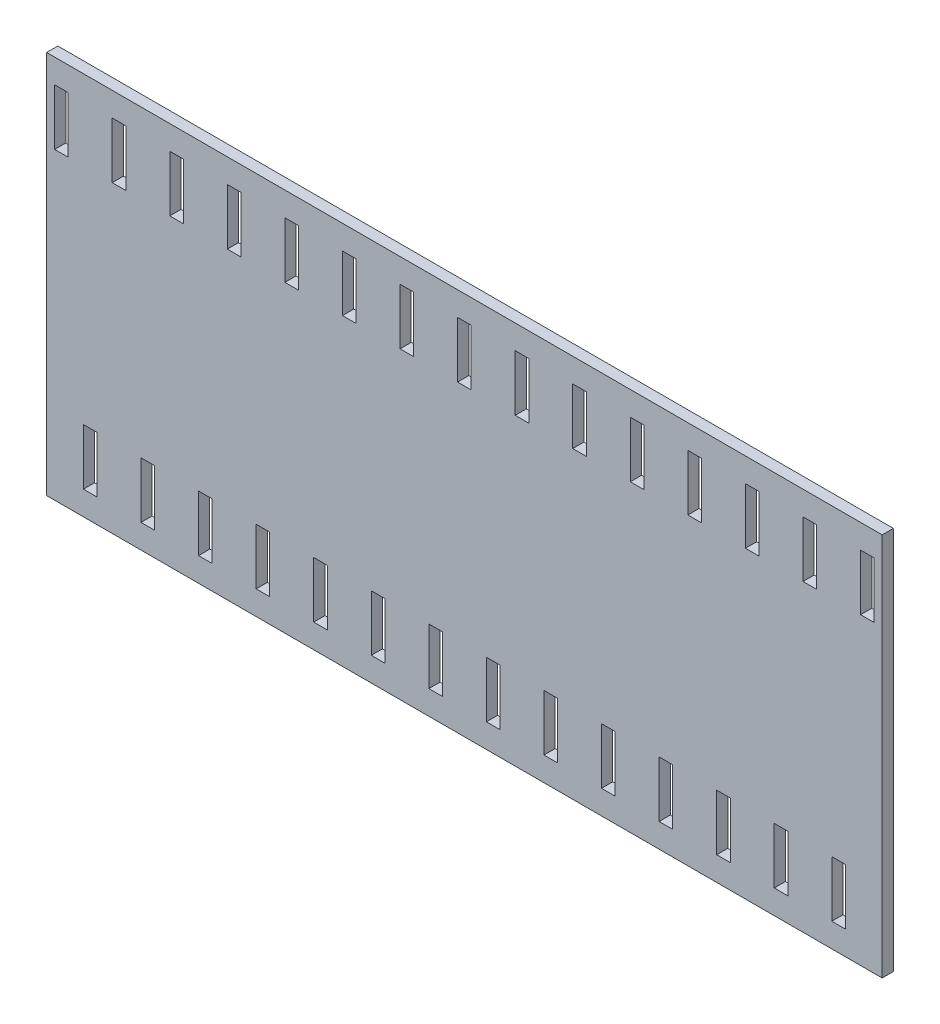
from build123d import *

# Parameters (mm, degrees)
ESQUISSE1_W             = 104.5
ESQUISSE1_H             = 48
BOSS_EXTRU_1_DEPTH      = 1.4
ESQUISSE2_W             = 1.7
ESQUISSE2_H             = 7
ENL_V_MAT_EXTRU_1_DEPTH = 2.4
ESQUISSE4_W             = 1.346153846
ESQUISSE4_H             = 0.358974359
ENL_V_MAT_EXTRU_2_DEPTH = 0.1


with BuildPart() as part:
    # Esquisse1 → Boss.-Extru.1 (new body)
    with BuildSketch(Plane.XY):
        Rectangle(ESQUISSE1_W, ESQUISSE1_H)
    extrude(amount=BOSS_EXTRU_1_DEPTH)

    # Esquisse2 → Enlèv. mat.-Extru.1 (cut, through all)
    with BuildSketch(Plane(origin=(0, 0, 0), x_dir=(-1, 0, 0), z_dir=(0, 0, -1))):
        with Locations((-50.4, 17.5)):
            Rectangle(ESQUISSE2_W, ESQUISSE2_H)
        with Locations((-43.2, 17.5)):
            Rectangle(ESQUISSE2_W, ESQUISSE2_H)
        with Locations((-36, 17.5)):
            Rectangle(ESQUISSE2_W, ESQUISSE2_H)
        with Locations((-28.8, 17.5)):
            Rectangle(ESQUISSE2_W, ESQUISSE2_H)
        with Locations((-21.6, 17.5)):
            Rectangle(ESQUISSE2_W, ESQUISSE2_H)
        with Locations((-14.4, 17.5)):
            Rectangle(ESQUISSE2_W, ESQUISSE2_H)
        with Locations((-7.2, 17.5)):
            Rectangle(ESQUISSE2_W, ESQUISSE2_H)
        with Locations((0, 17.5)):
            Rectangle(ESQUISSE2_W, ESQUISSE2_H)
        with Locations((7.2, 17.5)):
            Rectangle(ESQUISSE2_W, ESQUISSE2_H)
        with Locations((14.4, 17.5)):
            Rectangle(ESQUISSE2_W, ESQUISSE2_H)
        with Locations((21.6, 17.5)):
            Rectangle(ESQUISSE2_W, ESQUISSE2_H)
        with Locations((28.8, 17.5)):
            Rectangle(ESQUISSE2_W, ESQUISSE2_H)
        with Locations((36, 17.5)):
            Rectangle(ESQUISSE2_W, ESQUISSE2_H)
        with Locations((43.2, 17.5)):
            Rectangle(ESQUISSE2_W, ESQUISSE2_H)
        with Locations((50.4, 17.5)):
            Rectangle(ESQUISSE2_W, ESQUISSE2_H)
        with Locations((-46.8, -17.5)):
            Rectangle(ESQUISSE2_W, ESQUISSE2_H)
        with Locations((-39.6, -17.5)):
            Rectangle(ESQUISSE2_W, ESQUISSE2_H)
        with Locations((-32.4, -17.5)):
            Rectangle(ESQUISSE2_W, ESQUISSE2_H)
        with Locations((-25.2, -17.5)):
            Rectangle(ESQUISSE2_W, ESQUISSE2_H)
        with Locations((-18, -17.5)):
            Rectangle(ESQUISSE2_W, ESQUISSE2_H)
        with Locations((-10.8, -17.5)):
            Rectangle(ESQUISSE2_W, ESQUISSE2_H)
        with Locations((-3.6, -17.5)):
            Rectangle(ESQUISSE2_W, ESQUISSE2_H)
        with Locations((3.6, -17.5)):
            Rectangle(ESQUISSE2_W, ESQUISSE2_H)
        with Locations((10.8, -17.5)):
            Rectangle(ESQUISSE2_W, ESQUISSE2_H)
        with Locations((18, -17.5)):
            Rectangle(ESQUISSE2_W, ESQUISSE2_H)
        with Locations((25.2, -17.5)):
            Rectangle(ESQUISSE2_W, ESQUISSE2_H)
        with Locations((32.4, -17.5)):
            Rectangle(ESQUISSE2_W, ESQUISSE2_H)
        with Locations((39.6, -17.5)):
            Rectangle(ESQUISSE2_W, ESQUISSE2_H)
        with Locations((46.8, -17.5)):
            Rectangle(ESQUISSE2_W, ESQUISSE2_H)
    extrude(amount=-ENL_V_MAT_EXTRU_1_DEPTH, mode=Mode.SUBTRACT)

    # Esquisse4 → Enlèv. mat.-Extru.2 (cut)
    with BuildSketch(Plane(origin=(0, 0, 0), x_dir=(-1, 0, 0), z_dir=(0, 0, -1))):
        with BuildLine():
            Line((-12.952395535, 1.716787319), (-12.265997297, 1.716787319))
            add(Edge.make_bspline(
                [(-12.265997297, 1.716787319), (-12.218786391, 1.716735423), (-12.128328198, 1.716635987), (-11.998613143, 1.713621241), (-11.880803411, 1.709594549), (-11.77515303, 1.704012656), (-11.681336932, 1.697416066), (-11.599779632, 1.688164026), (-11.529840076, 1.678503731), (-11.487933627, 1.668682324), (-11.468821817, 1.664203184)],
                knots=[0, 0, 0, 0, 0.000141628, 0.000271366, 0.00038923, 0.000495248, 0.00058876, 0.000671296, 0.000741499, 0.00080036, 0.00080036, 0.00080036, 0.00080036], degree=3))
            add(Edge.make_bspline(
                [(-11.468821817, 1.664203184), (-11.444628283, 1.657581234), (-11.396811306, 1.644493373), (-11.327910262, 1.618279649), (-11.262356417, 1.587197484), (-11.199924859, 1.551773544), (-11.141382775, 1.51048798), (-11.085856735, 1.465014362), (-11.033836754, 1.414302794), (-10.985615362, 1.358922054), (-10.941330565, 1.299801844), (-10.903200882, 1.236059614), (-10.871273655, 1.168768311), (-10.843890383, 1.097974739), (-10.824181929, 1.023084416), (-10.809335029, 0.944617704), (-10.799911402, 0.862583013), (-10.79900884, 0.806523146), (-10.798549381, 0.777985235)],
                knots=[0, 0, 0, 0, 7.5216e-05, 0.00014866, 0.000220794, 0.000292713, 0.000363707, 0.000435434, 0.000507823, 0.000581364, 0.000655543, 0.000729131, 0.000803767, 0.000878771, 0.000956497, 0.001035702, 0.001118238, 0.001203821, 0.001203821, 0.001203821, 0.001203821], degree=3))
            add(Edge.make_bspline(
                [(-10.798549381, 0.777985235), (-10.798970805, 0.749207459), (-10.799795351, 0.692901795), (-10.809691637, 0.610529007), (-10.823021828, 0.531810616), (-10.843518881, 0.456921166), (-10.870364554, 0.386305395), (-10.901856607, 0.318884163), (-10.939840137, 0.255804492), (-10.983484967, 0.196837374), (-11.032036561, 0.141927462), (-11.085289499, 0.091472667), (-11.143028792, 0.045768329), (-11.20507094, 0.004711985), (-11.272020789, -0.030744294), (-11.342862942, -0.062501599), (-11.418213159, -0.08917266), (-11.470355673, -0.103202721), (-11.496866688, -0.110336079)],
                knots=[0, 0, 0, 0, 8.6284e-05, 0.00016882, 0.000248587, 0.000325638, 0.000401297, 0.000474998, 0.000548586, 0.000621785, 0.0006948, 0.0007682, 0.000841564, 0.000915458, 0.000991056, 0.00106858, 0.00114819, 0.001230532, 0.001230532, 0.001230532, 0.001230532], degree=3))
            add(Edge.make_bspline(
                [(-11.496866688, -0.110336079), (-11.518794022, -0.11499906), (-11.56684905, -0.125218254), (-11.645991772, -0.136626711), (-11.738137158, -0.146364311), (-11.843159438, -0.153665449), (-11.960964343, -0.159915817), (-12.0916156, -0.164883911), (-12.235369677, -0.167613765), (-12.335640921, -0.167754558), (-12.38799249, -0.167828066)],
                knots=[0, 0, 0, 0, 6.7238e-05, 0.000147357, 0.000239727, 0.000345177, 0.000463135, 0.000593636, 0.000737393, 0.000894446, 0.000894446, 0.000894446, 0.000894446], degree=3))
            Line((-12.38799249, -0.167828066), (-12.63829297, -0.167828066))
            Line((-12.63829297, -0.167828066), (-12.63829297, -1.783212681))
            Line((-12.63829297, -1.783212681), (-12.952395535, -1.783212681))
            Line((-12.952395535, -1.783212681), (-12.952395535, 1.716787319))
        make_face()
        with BuildLine():
            Line((-12.63829297, 1.35781296), (-12.63829297, 0.191146293))
            Line((-12.63829297, 0.191146293), (-12.025512522, 0.183433953))
            add(Edge.make_bspline(
                [(-12.025512522, 0.183433953), (-11.995592596, 0.18341849), (-11.937832796, 0.183388638), (-11.854396573, 0.187373861), (-11.776987285, 0.191974394), (-11.70584271, 0.198710317), (-11.640930776, 0.208231575), (-11.582143247, 0.217843313), (-11.529935964, 0.231748675), (-11.468836762, 0.250471744), (-11.400753415, 0.28240436), (-11.326685866, 0.32875425), (-11.26391528, 0.387834958), (-11.209596983, 0.45426279), (-11.166491105, 0.528161919), (-11.134935113, 0.607230856), (-11.116393955, 0.690658705), (-11.113907762, 0.747746844), (-11.112651945, 0.776582992)],
                knots=[0, 0, 0, 0, 8.9746e-05, 0.000173253, 0.000250533, 0.00032239, 0.000387534, 0.00044736, 0.000500926, 0.000549486, 0.000638903, 0.000725641, 0.000810488, 0.000896226, 0.000982324, 0.00106604, 0.001150757, 0.001237226, 0.001237226, 0.001237226, 0.001237226], degree=3))
            add(Edge.make_bspline(
                [(-11.112651945, 0.776582992), (-11.113914591, 0.804721505), (-11.116424576, 0.860657387), (-11.135080439, 0.942636148), (-11.166429753, 1.020871852), (-11.209886348, 1.093844938), (-11.262627478, 1.160033742), (-11.323926821, 1.217530869), (-11.393640082, 1.263752572), (-11.458488313, 1.293585853), (-11.516089499, 1.311801129), (-11.566121459, 1.324545969), (-11.622612134, 1.334721575), (-11.685579913, 1.342961078), (-11.754536747, 1.350014539), (-11.830075062, 1.354800517), (-11.911908705, 1.357601973), (-11.968719276, 1.357740928), (-11.998168772, 1.35781296)],
                knots=[0, 0, 0, 0, 8.4371e-05, 0.000167719, 0.000250783, 0.000336277, 0.000421575, 0.000503926, 0.000587348, 0.000671427, 0.000717102, 0.000768457, 0.000826213, 0.000889178, 0.000958942, 0.001034123, 0.001116202, 0.001204546, 0.001204546, 0.001204546, 0.001204546], degree=3))
            Line((-11.998168772, 1.35781296), (-12.63829297, 1.35781296))
        make_face(mode=Mode.SUBTRACT)
        with BuildLine():
            Line((-6.849831432, 1.074559755), (-7.124671176, 0.864223216))
            add(Edge.make_bspline(
                [(-7.124671176, 0.864223216), (-7.144277064, 0.887589186), (-7.183224511, 0.934006102), (-7.245883713, 0.999185646), (-7.311185356, 1.060250908), (-7.379104477, 1.117492787), (-7.450863597, 1.168909553), (-7.524724396, 1.217180656), (-7.601922441, 1.260448394), (-7.708674175, 1.31291138), (-7.848322024, 1.367657535), (-8.024116863, 1.413560766), (-8.207627961, 1.442781942), (-8.332825561, 1.445946783), (-8.396506111, 1.44755655)],
                knots=[0, 0, 0, 0, 9.1485e-05, 0.000181737, 0.000271024, 0.000359627, 0.000447979, 0.000535687, 0.000624217, 0.000713268, 0.000892422, 0.00107303, 0.001257466, 0.001448389, 0.001448389, 0.001448389, 0.001448389], degree=3))
            add(Edge.make_bspline(
                [(-8.396506111, 1.44755655), (-8.431589411, 1.447152587), (-8.501430403, 1.446348411), (-8.605078877, 1.435739286), (-8.706791928, 1.420828076), (-8.806503394, 1.398702753), (-8.904086353, 1.370730134), (-9.000178755, 1.33730472), (-9.093389355, 1.29594988), (-9.185007593, 1.25024162), (-9.272786804, 1.198614175), (-9.355841852, 1.142300823), (-9.43386982, 1.081931727), (-9.506932432, 1.01728062), (-9.57510438, 0.94863866), (-9.637891691, 0.875274318), (-9.695077101, 0.797422145), (-9.747794126, 0.716108737), (-9.795006859, 0.631570946), (-9.834536739, 0.543495875), (-9.869541861, 0.453391772), (-9.897241104, 0.360240611), (-9.919165621, 0.264697846), (-9.934293284, 0.166507058), (-9.944781755, 0.065873378), (-9.945581932, -0.002335935), (-9.945985278, -0.03671829)],
                knots=[0, 0, 0, 0, 0.000105206, 0.000209435, 0.000312261, 0.00041348, 0.000515565, 0.000616682, 0.000718413, 0.000821258, 0.000923708, 0.001023662, 0.001122111, 0.001219464, 0.00131614, 0.001412112, 0.001508869, 0.001605718, 0.001702691, 0.001799013, 0.001895107, 0.001992482, 0.002090281, 0.00218895, 0.002290387, 0.00239349, 0.00239349, 0.00239349, 0.00239349], degree=3))
            add(Edge.make_bspline(
                [(-9.945985278, -0.03671829), (-9.944723459, -0.08844961), (-9.942246045, -0.190017195), (-9.920197711, -0.338787806), (-9.886692619, -0.481308479), (-9.836477042, -0.616688322), (-9.774557992, -0.74659668), (-9.69631738, -0.868835533), (-9.605700843, -0.985252098), (-9.501426424, -1.093095045), (-9.387020608, -1.191608771), (-9.264272696, -1.278359352), (-9.133488408, -1.350674235), (-8.996111778, -1.410850181), (-8.851085664, -1.457106909), (-8.698670862, -1.489671032), (-8.539198866, -1.510913213), (-8.430229467, -1.512946901), (-8.374771336, -1.513981912)],
                knots=[0, 0, 0, 0, 0.000155106, 0.000304531, 0.000450265, 0.000593548, 0.000736853, 0.000881182, 0.001028026, 0.001178769, 0.001330408, 0.001480379, 0.001628835, 0.001777978, 0.001929641, 0.002084627, 0.002245075, 0.00241136, 0.00241136, 0.00241136, 0.00241136], degree=3))
            add(Edge.make_bspline(
                [(-8.374771336, -1.513981912), (-8.313668647, -1.512293132), (-8.193403938, -1.50896921), (-8.017035912, -1.480809961), (-7.848200146, -1.435152043), (-7.686887559, -1.37125412), (-7.533552913, -1.288188833), (-7.387956253, -1.187490955), (-7.249974682, -1.068202622), (-7.1670034, -0.977119494), (-7.124671176, -0.930648579)],
                knots=[0, 0, 0, 0, 0.00018322, 0.00036062, 0.000534275, 0.000707044, 0.000879893, 0.001056289, 0.001237208, 0.001425665, 0.001425665, 0.001425665, 0.001425665], degree=3))
            Line((-7.124671176, -0.930648579), (-6.849831432, -1.138881752))
            add(Edge.make_bspline(
                [(-6.849831432, -1.138881752), (-6.871949542, -1.167420204), (-6.916079817, -1.22436041), (-6.987537834, -1.30463212), (-7.062815131, -1.380136155), (-7.142470841, -1.450263776), (-7.225588633, -1.516418242), (-7.313660945, -1.576720073), (-7.405529978, -1.632010958), (-7.500884457, -1.682637882), (-7.59962307, -1.727555129), (-7.701627505, -1.766008897), (-7.80645808, -1.799133786), (-7.914119588, -1.826385723), (-8.024835345, -1.847656807), (-8.138205819, -1.861876482), (-8.254475695, -1.871618396), (-8.332917116, -1.872506312), (-8.37266797, -1.872956271)],
                knots=[0, 0, 0, 0, 0.000108293, 0.000216068, 0.000322162, 0.000427957, 0.000534281, 0.00064066, 0.000747915, 0.000855806, 0.000964371, 0.001073102, 0.001182643, 0.001294024, 0.001406092, 0.001520624, 0.001636667, 0.001755891, 0.001755891, 0.001755891, 0.001755891], degree=3))
            add(Edge.make_bspline(
                [(-8.37266797, -1.872956271), (-8.410311637, -1.872694278), (-8.484747328, -1.872176221), (-8.594646079, -1.863784053), (-8.70163566, -1.852334316), (-8.805410286, -1.835094185), (-8.906536261, -1.814749845), (-9.004096845, -1.787478589), (-9.099052056, -1.756929422), (-9.191020396, -1.721024435), (-9.280080096, -1.680508253), (-9.365943908, -1.634716694), (-9.44857234, -1.584034829), (-9.528777761, -1.529579819), (-9.605375345, -1.469602517), (-9.67902887, -1.404935882), (-9.750151346, -1.335797872), (-9.794154031, -1.285943018), (-9.816277746, -1.260876944)],
                knots=[0, 0, 0, 0, 0.0001129, 0.000223246, 0.000330481, 0.000435603, 0.000538732, 0.000639764, 0.000739316, 0.000837878, 0.000935767, 0.001032686, 0.001129604, 0.00122645, 0.001323362, 0.001421241, 0.001520399, 0.001620667, 0.001620667, 0.001620667, 0.001620667], degree=3))
            add(Edge.make_bspline(
                [(-9.816277746, -1.260876944), (-9.85171339, -1.217335755), (-9.922156866, -1.130779045), (-10.01228255, -0.990493063), (-10.089430105, -0.844024855), (-10.151806026, -0.690604926), (-10.200568759, -0.530577539), (-10.234349954, -0.363862024), (-10.256301559, -0.190614082), (-10.258811847, -0.072777293), (-10.260087842, -0.012880149)],
                knots=[0, 0, 0, 0, 0.000168306, 0.00033458, 0.000499224, 0.000664315, 0.00083066, 0.00100034, 0.001174094, 0.001353718, 0.001353718, 0.001353718, 0.001353718], degree=3))
            add(Edge.make_bspline(
                [(-10.260087842, -0.012880149), (-10.258532649, 0.050075304), (-10.255472902, 0.173936229), (-10.229477107, 0.355710182), (-10.187658311, 0.529861581), (-10.128261422, 0.696065326), (-10.052956071, 0.855195606), (-9.959929457, 1.006036811), (-9.850262315, 1.14955361), (-9.724814747, 1.283568362), (-9.587247412, 1.406107714), (-9.439928598, 1.513913918), (-9.283146651, 1.603631434), (-9.118628799, 1.678627596), (-8.945143118, 1.73627206), (-8.763059749, 1.776625246), (-8.572720834, 1.801742363), (-8.442858408, 1.80491757), (-8.376874701, 1.806530909)],
                knots=[0, 0, 0, 0, 0.000188789, 0.000371431, 0.000549644, 0.000725278, 0.00089996, 0.001076844, 0.001255917, 0.001440951, 0.001626689, 0.001807878, 0.001987546, 0.002167657, 0.002349462, 0.002534866, 0.002726448, 0.002924344, 0.002924344, 0.002924344, 0.002924344], degree=3))
            add(Edge.make_bspline(
                [(-8.376874701, 1.806530909), (-8.336660229, 1.80604877), (-8.257059732, 1.805094426), (-8.13930708, 1.795788284), (-8.024664753, 1.780274678), (-7.913053771, 1.759158608), (-7.803931154, 1.732951287), (-7.698130913, 1.698810988), (-7.595032227, 1.659774457), (-7.495285318, 1.614815991), (-7.399368768, 1.56434925), (-7.30731245, 1.508933626), (-7.219847591, 1.448637821), (-7.136358743, 1.383974645), (-7.058242532, 1.313576086), (-6.983281053, 1.23937849), (-6.914019975, 1.159244666), (-6.87126678, 1.102839732), (-6.849831432, 1.074559755)],
                knots=[0, 0, 0, 0, 0.000120626, 0.000238766, 0.000354085, 0.000467531, 0.000579423, 0.000690512, 0.000800803, 0.000910007, 0.001018518, 0.001125773, 0.001232152, 0.001337058, 0.001442329, 0.001547432, 0.001653292, 0.001759736, 0.001759736, 0.001759736, 0.001759736], degree=3))
        make_face()
        with BuildLine():
            Line((-6.131882714, 1.716787319), (-5.448990086, 1.716787319))
            add(Edge.make_bspline(
                [(-5.448990086, 1.716787319), (-5.415561608, 1.716611568), (-5.350768897, 1.71627092), (-5.256549455, 1.710987789), (-5.168300645, 1.703784119), (-5.085996872, 1.692354027), (-5.00967617, 1.67856225), (-4.939108533, 1.661860433), (-4.874518361, 1.64183382), (-4.797405624, 1.609987539), (-4.709484963, 1.56266437), (-4.614286571, 1.492735805), (-4.532882331, 1.407203342), (-4.462696014, 1.310720687), (-4.406894894, 1.204584915), (-4.366525597, 1.091325726), (-4.340967722, 0.972403984), (-4.338339287, 0.890760806), (-4.337010919, 0.849499659)],
                knots=[0, 0, 0, 0, 0.00010027, 0.000194349, 0.000283026, 0.000365821, 0.000443519, 0.000515622, 0.000583254, 0.00064614, 0.000765662, 0.000881909, 0.000998927, 0.001118415, 0.001238844, 0.00135727, 0.001478274, 0.001601912, 0.001601912, 0.001601912, 0.001601912], degree=3))
            add(Edge.make_bspline(
                [(-4.337010919, 0.849499659), (-4.338104138, 0.810847103), (-4.340252415, 0.734891186), (-4.360795174, 0.623797077), (-4.392955843, 0.518045858), (-4.437661092, 0.418023472), (-4.495763088, 0.325989859), (-4.564621407, 0.241202593), (-4.647698209, 0.167251536), (-4.709941449, 0.125908634), (-4.741558195, 0.104908312)],
                knots=[0, 0, 0, 0, 0.000115857, 0.00022767, 0.000337672, 0.000446877, 0.000555233, 0.000663318, 0.000773539, 0.000887324, 0.000887324, 0.000887324, 0.000887324], degree=3))
            add(Edge.make_bspline(
                [(-4.741558195, 0.104908312), (-4.701797767, 0.089643313), (-4.62572622, 0.060437589), (-4.521040207, 0.008802125), (-4.430845362, -0.047359985), (-4.354448216, -0.108691836), (-4.289110561, -0.174800646), (-4.23205762, -0.246655761), (-4.183376246, -0.325194518), (-4.141663322, -0.409598054), (-4.109114566, -0.499004522), (-4.084738662, -0.592575298), (-4.070771213, -0.689974853), (-4.068783571, -0.756260233), (-4.06778015, -0.789723098)],
                knots=[0, 0, 0, 0, 0.000127722, 0.000244363, 0.000349599, 0.000445847, 0.000537565, 0.000627901, 0.000720503, 0.000814257, 0.000909859, 0.001005428, 0.001103887, 0.001204268, 0.001204268, 0.001204268, 0.001204268], degree=3))
            add(Edge.make_bspline(
                [(-4.06778015, -0.789723098), (-4.068756996, -0.82388997), (-4.070678968, -0.891114248), (-4.08485894, -0.989869383), (-4.108868047, -1.084244329), (-4.141939193, -1.174849512), (-4.185101508, -1.261509646), (-4.237629472, -1.34432291), (-4.300261036, -1.422457241), (-4.370323904, -1.496780864), (-4.44958605, -1.563608652), (-4.535101805, -1.623124358), (-4.627948125, -1.67207042), (-4.726600119, -1.713186442), (-4.832164435, -1.74459364), (-4.944167042, -1.766566214), (-5.062511344, -1.781371251), (-5.143721095, -1.782588456), (-5.185368291, -1.783212681)],
                knots=[0, 0, 0, 0, 0.000102481, 0.000201635, 0.000298562, 0.000394165, 0.000490425, 0.000588455, 0.000687769, 0.000790423, 0.000894381, 0.000998232, 0.001102369, 0.001208616, 0.001318415, 0.001432129, 0.001550749, 0.00167562, 0.00167562, 0.00167562, 0.00167562], degree=3))
            Line((-5.185368291, -1.783212681), (-6.131882714, -1.783212681))
            Line((-6.131882714, -1.783212681), (-6.131882714, 1.716787319))
        make_face()
        with BuildLine():
            Line((-5.81778015, 1.35781296), (-5.81778015, 0.236018088))
            Line((-5.81778015, 0.236018088), (-5.60674249, 0.236018088))
            add(Edge.make_bspline(
                [(-5.60674249, 0.236018088), (-5.575893694, 0.236418011), (-5.516287535, 0.237190744), (-5.429967638, 0.239404261), (-5.34984262, 0.245602304), (-5.276050787, 0.251798566), (-5.208708343, 0.261873154), (-5.147964482, 0.273865277), (-5.092865885, 0.286548182), (-5.029326339, 0.308117669), (-4.957253391, 0.339995344), (-4.880420287, 0.38946718), (-4.812685817, 0.448391533), (-4.755488629, 0.516382495), (-4.708677159, 0.591248681), (-4.676163444, 0.671795561), (-4.654116159, 0.756015693), (-4.652124628, 0.813833946), (-4.651113483, 0.843189562)],
                knots=[0, 0, 0, 0, 9.2559e-05, 0.000178842, 0.000258967, 0.000333616, 0.000400942, 0.000463093, 0.000519379, 0.000570374, 0.000664201, 0.000755025, 0.000843472, 0.000932526, 0.001020669, 0.001107124, 0.001192318, 0.001280185, 0.001280185, 0.001280185, 0.001280185], degree=3))
            add(Edge.make_bspline(
                [(-4.651113483, 0.843189562), (-4.651639663, 0.862615334), (-4.652671823, 0.900721106), (-4.661125126, 0.95627046), (-4.6754927, 1.008514213), (-4.693946994, 1.058168323), (-4.719735682, 1.103680173), (-4.750099146, 1.146623369), (-4.786784836, 1.185535487), (-4.828542149, 1.221904986), (-4.876550771, 1.254149513), (-4.930782063, 1.282390277), (-4.99196974, 1.305131053), (-5.059082595, 1.325047206), (-5.133153683, 1.3390355), (-5.213328236, 1.350688887), (-5.300262955, 1.356621629), (-5.360408058, 1.357406992), (-5.391498099, 1.35781296)],
                knots=[0, 0, 0, 0, 5.8261e-05, 0.000114285, 0.000168029, 0.000220632, 0.000272728, 0.000324483, 0.000378062, 0.000432741, 0.000490301, 0.000551137, 0.000615721, 0.000685833, 0.000760908, 0.00084162, 0.000928788, 0.00102206, 0.00102206, 0.00102206, 0.00102206], degree=3))
            Line((-5.391498099, 1.35781296), (-5.81778015, 1.35781296))
        make_face(mode=Mode.SUBTRACT)
        with BuildLine():
            Line((-5.81778015, -0.122956271), (-5.81778015, -1.424238322))
            Line((-5.81778015, -1.424238322), (-5.370464445, -1.424238322))
            add(Edge.make_bspline(
                [(-5.370464445, -1.424238322), (-5.338445519, -1.423854575), (-5.27673326, -1.423114952), (-5.18763203, -1.420700398), (-5.105048926, -1.415208122), (-5.029360791, -1.406562272), (-4.959750338, -1.397183823), (-4.897052635, -1.384572542), (-4.840759442, -1.370123582), (-4.775485134, -1.34778941), (-4.701981625, -1.313092939), (-4.622770769, -1.260778712), (-4.552344551, -1.198455404), (-4.492539292, -1.12632449), (-4.443526303, -1.047893163), (-4.407870848, -0.964747813), (-4.385879991, -0.878262286), (-4.383217822, -0.819295573), (-4.381882714, -0.789723098)],
                knots=[0, 0, 0, 0, 9.6064e-05, 0.000185151, 0.000267373, 0.000344257, 0.000413665, 0.000478015, 0.000536005, 0.000587888, 0.000684801, 0.000778918, 0.000871787, 0.000965866, 0.001059062, 0.00114827, 0.001236355, 0.001324974, 0.001324974, 0.001324974, 0.001324974], degree=3))
            add(Edge.make_bspline(
                [(-4.381882714, -0.789723098), (-4.382158818, -0.771229757), (-4.382706573, -0.734541376), (-4.390967188, -0.680625556), (-4.402981058, -0.628399683), (-4.418512492, -0.577721943), (-4.441131959, -0.529508566), (-4.467538504, -0.482806007), (-4.498499906, -0.437552527), (-4.546744072, -0.380340274), (-4.616916056, -0.314423261), (-4.716622832, -0.249885759), (-4.82999513, -0.197837952), (-4.912222622, -0.175738475), (-4.95469922, -0.164322457)],
                knots=[0, 0, 0, 0, 5.5429e-05, 0.000109963, 0.000163198, 0.000216191, 0.000268588, 0.000322593, 0.000377046, 0.000432793, 0.000546889, 0.000664343, 0.000787646, 0.000919405, 0.000919405, 0.000919405, 0.000919405], degree=3))
            add(Edge.make_bspline(
                [(-4.95469922, -0.164322457), (-4.971728316, -0.160867373), (-5.008650909, -0.153376038), (-5.068858489, -0.145468335), (-5.137594358, -0.138423275), (-5.215017235, -0.133212117), (-5.301225076, -0.127825574), (-5.396401995, -0.125730753), (-5.50015931, -0.123231493), (-5.572151682, -0.123050358), (-5.609546977, -0.122956271)],
                knots=[0, 0, 0, 0, 5.2115e-05, 0.000112995, 0.000182062, 0.000259389, 0.000345767, 0.00044116, 0.000544948, 0.000657129, 0.000657129, 0.000657129, 0.000657129], degree=3))
            Line((-5.609546977, -0.122956271), (-5.81778015, -0.122956271))
        make_face(mode=Mode.SUBTRACT)
        with Locations((-1.644703227, -0.437058836)):
            Rectangle(ESQUISSE4_W, ESQUISSE4_H)
        with BuildLine():
            Line((0.957860876, 1.716787319), (1.644259113, 1.716787319))
            add(Edge.make_bspline(
                [(1.644259113, 1.716787319), (1.691470019, 1.716735423), (1.781928212, 1.716635987), (1.911643268, 1.713621241), (2.029452999, 1.709594549), (2.13510338, 1.704012656), (2.228919478, 1.697416066), (2.310476778, 1.688164026), (2.380416334, 1.678503731), (2.422322784, 1.668682324), (2.441434594, 1.664203184)],
                knots=[0, 0, 0, 0, 0.000141628, 0.000271366, 0.00038923, 0.000495248, 0.00058876, 0.000671296, 0.000741499, 0.00080036, 0.00080036, 0.00080036, 0.00080036], degree=3))
            add(Edge.make_bspline(
                [(2.441434594, 1.664203184), (2.465628127, 1.657581234), (2.513445105, 1.644493373), (2.582346148, 1.618279649), (2.647899993, 1.587197484), (2.710331552, 1.551773544), (2.768873635, 1.51048798), (2.824399676, 1.465014362), (2.876419656, 1.414302794), (2.924641048, 1.358922054), (2.968925846, 1.299801844), (3.007055528, 1.236059614), (3.038982755, 1.168768311), (3.066366027, 1.097974739), (3.086074481, 1.023084416), (3.100921381, 0.944617704), (3.110345009, 0.862583013), (3.11124757, 0.806523146), (3.11170703, 0.777985235)],
                knots=[0, 0, 0, 0, 7.5216e-05, 0.00014866, 0.000220794, 0.000292713, 0.000363707, 0.000435434, 0.000507823, 0.000581364, 0.000655543, 0.000729131, 0.000803767, 0.000878771, 0.000956497, 0.001035702, 0.001118238, 0.001203821, 0.001203821, 0.001203821, 0.001203821], degree=3))
            add(Edge.make_bspline(
                [(3.11170703, 0.777985235), (3.111285605, 0.749207459), (3.110461059, 0.692901795), (3.100564774, 0.610529007), (3.087234582, 0.531810616), (3.06673753, 0.456921166), (3.039891857, 0.386305395), (3.008399804, 0.318884163), (2.970416273, 0.255804492), (2.926771444, 0.196837374), (2.878219849, 0.141927462), (2.824966911, 0.091472667), (2.767227619, 0.045768329), (2.70518547, 0.004711985), (2.638235622, -0.030744294), (2.567393468, -0.062501599), (2.492043252, -0.08917266), (2.439900738, -0.103202721), (2.413389722, -0.110336079)],
                knots=[0, 0, 0, 0, 8.6284e-05, 0.00016882, 0.000248587, 0.000325638, 0.000401297, 0.000474998, 0.000548586, 0.000621785, 0.0006948, 0.0007682, 0.000841564, 0.000915458, 0.000991056, 0.00106858, 0.00114819, 0.001230532, 0.001230532, 0.001230532, 0.001230532], degree=3))
            add(Edge.make_bspline(
                [(2.413389722, -0.110336079), (2.391462388, -0.11499906), (2.343407361, -0.125218254), (2.264264638, -0.136626711), (2.172119252, -0.146364311), (2.067096973, -0.153665449), (1.949292068, -0.159915817), (1.81864081, -0.164883911), (1.674886733, -0.167613765), (1.574615489, -0.167754558), (1.522263921, -0.167828066)],
                knots=[0, 0, 0, 0, 6.7238e-05, 0.000147357, 0.000239727, 0.000345177, 0.000463135, 0.000593636, 0.000737393, 0.000894446, 0.000894446, 0.000894446, 0.000894446], degree=3))
            Line((1.522263921, -0.167828066), (1.27196344, -0.167828066))
            Line((1.27196344, -0.167828066), (1.27196344, -1.783212681))
            Line((1.27196344, -1.783212681), (0.957860876, -1.783212681))
            Line((0.957860876, -1.783212681), (0.957860876, 1.716787319))
        make_face()
        with BuildLine():
            Line((1.27196344, 1.35781296), (1.27196344, 0.191146293))
            Line((1.27196344, 0.191146293), (1.884743889, 0.183433953))
            add(Edge.make_bspline(
                [(1.884743889, 0.183433953), (1.914663814, 0.18341849), (1.972423614, 0.183388638), (2.055859838, 0.187373861), (2.133269125, 0.191974394), (2.2044137, 0.198710317), (2.269325635, 0.208231575), (2.328113164, 0.217843313), (2.380320446, 0.231748675), (2.441419648, 0.250471744), (2.509502996, 0.28240436), (2.583570544, 0.32875425), (2.646341131, 0.387834958), (2.700659427, 0.45426279), (2.743765305, 0.528161919), (2.775321298, 0.607230856), (2.793862455, 0.690658705), (2.796348649, 0.747746844), (2.797604465, 0.776582992)],
                knots=[0, 0, 0, 0, 8.9746e-05, 0.000173253, 0.000250533, 0.00032239, 0.000387534, 0.00044736, 0.000500926, 0.000549486, 0.000638903, 0.000725641, 0.000810488, 0.000896226, 0.000982324, 0.00106604, 0.001150757, 0.001237226, 0.001237226, 0.001237226, 0.001237226], degree=3))
            add(Edge.make_bspline(
                [(2.797604465, 0.776582992), (2.796341819, 0.804721505), (2.793831834, 0.860657387), (2.775175971, 0.942636148), (2.743826657, 1.020871852), (2.700370062, 1.093844938), (2.647628933, 1.160033742), (2.586329589, 1.217530869), (2.516616328, 1.263752572), (2.451768097, 1.293585853), (2.394166911, 1.311801129), (2.344134951, 1.324545969), (2.287644277, 1.334721575), (2.224676497, 1.342961078), (2.155719663, 1.350014539), (2.080181348, 1.354800517), (1.998347705, 1.357601973), (1.941537134, 1.357740928), (1.912087639, 1.35781296)],
                knots=[0, 0, 0, 0, 8.4371e-05, 0.000167719, 0.000250783, 0.000336277, 0.000421575, 0.000503926, 0.000587348, 0.000671427, 0.000717102, 0.000768457, 0.000826213, 0.000889178, 0.000958942, 0.001034123, 0.001116202, 0.001204546, 0.001204546, 0.001204546, 0.001204546], degree=3))
            Line((1.912087639, 1.35781296), (1.27196344, 1.35781296))
        make_face(mode=Mode.SUBTRACT)
        Polygon((5.265553183, 1.716787319), (6.880937799, -1.783212681), (6.539491485, -1.783212681), (6.0220636, -0.661417809), (4.435424978, -0.661417809), (3.903273536, -1.783212681), (3.560424978, -1.783212681), (5.220681389, 1.716787319), align=None)
        Polygon((5.239611677, 1.034595812), (4.605797574, -0.30244345), (5.856598857, -0.30244345), align=None, mode=Mode.SUBTRACT)
        with BuildLine():
            Line((7.509142927, 1.716787319), (8.195541164, 1.716787319))
            add(Edge.make_bspline(
                [(8.195541164, 1.716787319), (8.24275207, 1.716735423), (8.333210263, 1.716635987), (8.462925319, 1.713621241), (8.58073505, 1.709594549), (8.686385431, 1.704012656), (8.78020153, 1.697416066), (8.861758829, 1.688164026), (8.931698385, 1.678503731), (8.973604835, 1.668682324), (8.992716645, 1.664203184)],
                knots=[0, 0, 0, 0, 0.000141628, 0.000271366, 0.00038923, 0.000495248, 0.00058876, 0.000671296, 0.000741499, 0.00080036, 0.00080036, 0.00080036, 0.00080036], degree=3))
            add(Edge.make_bspline(
                [(8.992716645, 1.664203184), (9.016910179, 1.657581234), (9.064727156, 1.644493373), (9.133628199, 1.618279649), (9.199182045, 1.587197484), (9.261613603, 1.551773544), (9.320155686, 1.51048798), (9.375681727, 1.465014362), (9.427701707, 1.414302794), (9.475923099, 1.358922054), (9.520207897, 1.299801844), (9.55833758, 1.236059614), (9.590264807, 1.168768311), (9.617648078, 1.097974739), (9.637356533, 1.023084416), (9.652203432, 0.944617704), (9.66162706, 0.862583013), (9.662529622, 0.806523146), (9.662989081, 0.777985235)],
                knots=[0, 0, 0, 0, 7.5216e-05, 0.00014866, 0.000220794, 0.000292713, 0.000363707, 0.000435434, 0.000507823, 0.000581364, 0.000655543, 0.000729131, 0.000803767, 0.000878771, 0.000956497, 0.001035702, 0.001118238, 0.001203821, 0.001203821, 0.001203821, 0.001203821], degree=3))
            add(Edge.make_bspline(
                [(9.662989081, 0.777985235), (9.662567656, 0.749207459), (9.66174311, 0.692901795), (9.651846825, 0.610529007), (9.638516633, 0.531810616), (9.618019581, 0.456921166), (9.591173908, 0.386305395), (9.559681855, 0.318884163), (9.521698325, 0.255804492), (9.478053495, 0.196837374), (9.429501901, 0.141927462), (9.376248962, 0.091472667), (9.31850967, 0.045768329), (9.256467522, 0.004711985), (9.189517673, -0.030744294), (9.118675519, -0.062501599), (9.043325303, -0.08917266), (8.991182789, -0.103202721), (8.964671773, -0.110336079)],
                knots=[0, 0, 0, 0, 8.6284e-05, 0.00016882, 0.000248587, 0.000325638, 0.000401297, 0.000474998, 0.000548586, 0.000621785, 0.0006948, 0.0007682, 0.000841564, 0.000915458, 0.000991056, 0.00106858, 0.00114819, 0.001230532, 0.001230532, 0.001230532, 0.001230532], degree=3))
            add(Edge.make_bspline(
                [(8.964671773, -0.110336079), (8.942744439, -0.11499906), (8.894689412, -0.125218254), (8.81554669, -0.136626711), (8.723401304, -0.146364311), (8.618379024, -0.153665449), (8.500574119, -0.159915817), (8.369922862, -0.164883911), (8.226168784, -0.167613765), (8.12589754, -0.167754558), (8.073545972, -0.167828066)],
                knots=[0, 0, 0, 0, 6.7238e-05, 0.000147357, 0.000239727, 0.000345177, 0.000463135, 0.000593636, 0.000737393, 0.000894446, 0.000894446, 0.000894446, 0.000894446], degree=3))
            Line((8.073545972, -0.167828066), (7.823245491, -0.167828066))
            Line((7.823245491, -0.167828066), (7.823245491, -1.783212681))
            Line((7.823245491, -1.783212681), (7.509142927, -1.783212681))
            Line((7.509142927, -1.783212681), (7.509142927, 1.716787319))
        make_face()
        with BuildLine():
            Line((7.823245491, 1.35781296), (7.823245491, 0.191146293))
            Line((7.823245491, 0.191146293), (8.43602594, 0.183433953))
            add(Edge.make_bspline(
                [(8.43602594, 0.183433953), (8.465945866, 0.18341849), (8.523705666, 0.183388638), (8.607141889, 0.187373861), (8.684551176, 0.191974394), (8.755695751, 0.198710317), (8.820607686, 0.208231575), (8.879395215, 0.217843313), (8.931602498, 0.231748675), (8.9927017, 0.250471744), (9.060785047, 0.28240436), (9.134852596, 0.32875425), (9.197623182, 0.387834958), (9.251941479, 0.45426279), (9.295047357, 0.528161919), (9.326603349, 0.607230856), (9.345144506, 0.690658705), (9.3476307, 0.747746844), (9.348886517, 0.776582992)],
                knots=[0, 0, 0, 0, 8.9746e-05, 0.000173253, 0.000250533, 0.00032239, 0.000387534, 0.00044736, 0.000500926, 0.000549486, 0.000638903, 0.000725641, 0.000810488, 0.000896226, 0.000982324, 0.00106604, 0.001150757, 0.001237226, 0.001237226, 0.001237226, 0.001237226], degree=3))
            add(Edge.make_bspline(
                [(9.348886517, 0.776582992), (9.34762387, 0.804721505), (9.345113885, 0.860657387), (9.326458022, 0.942636148), (9.295108708, 1.020871852), (9.251652114, 1.093844938), (9.198910984, 1.160033742), (9.137611641, 1.217530869), (9.067898379, 1.263752572), (9.003050148, 1.293585853), (8.945448962, 1.311801129), (8.895417002, 1.324545969), (8.838926328, 1.334721575), (8.775958548, 1.342961078), (8.707001715, 1.350014539), (8.6314634, 1.354800517), (8.549629756, 1.357601973), (8.492819186, 1.357740928), (8.46336969, 1.35781296)],
                knots=[0, 0, 0, 0, 8.4371e-05, 0.000167719, 0.000250783, 0.000336277, 0.000421575, 0.000503926, 0.000587348, 0.000671427, 0.000717102, 0.000768457, 0.000826213, 0.000889178, 0.000958942, 0.001034123, 0.001116202, 0.001204546, 0.001204546, 0.001204546, 0.001204546], degree=3))
            Line((8.46336969, 1.35781296), (7.823245491, 1.35781296))
        make_face(mode=Mode.SUBTRACT)
        Polygon((10.380937799, 1.716787319), (12.355296773, 1.716787319), (12.355296773, 1.35781296), (10.695040363, 1.35781296), (10.695040363, 0.280889883), (12.355296773, 0.280889883), (12.355296773, -0.078084476), (10.695040363, -0.078084476), (10.695040363, -1.424238322), (12.355296773, -1.424238322), (12.355296773, -1.783212681), (10.380937799, -1.783212681), align=None)
        with BuildLine():
            Line((12.983501901, 1.716787319), (13.683922574, 1.716787319))
            add(Edge.make_bspline(
                [(13.683922574, 1.716787319), (13.730663703, 1.716631733), (13.820411847, 1.71633299), (13.948985118, 1.714667228), (14.065812215, 1.709892872), (14.170832054, 1.705784288), (14.264042709, 1.698292347), (14.34573, 1.6911317), (14.415517697, 1.681758039), (14.457763549, 1.673052616), (14.476891324, 1.669111037)],
                knots=[0, 0, 0, 0, 0.000140226, 0.00026925, 0.000385712, 0.000490995, 0.000584507, 0.000666202, 0.000736998, 0.000795574, 0.000795574, 0.000795574, 0.000795574], degree=3))
            add(Edge.make_bspline(
                [(14.476891324, 1.669111037), (14.502497949, 1.662784271), (14.553164938, 1.650265708), (14.626115004, 1.623806107), (14.695629328, 1.593186482), (14.761419152, 1.557222762), (14.823154944, 1.515647982), (14.881473254, 1.46917986), (14.936638718, 1.418072654), (14.986420348, 1.361037813), (15.0333594, 1.301201303), (15.072948026, 1.236497546), (15.107074506, 1.168836019), (15.134245023, 1.097528601), (15.156122996, 1.023266829), (15.171549236, 0.945378032), (15.180800423, 0.864217057), (15.181742279, 0.808859148), (15.18221985, 0.780789723)],
                knots=[0, 0, 0, 0, 7.9081e-05, 0.000156475, 0.000232432, 0.000306798, 0.00038108, 0.000455429, 0.000530331, 0.000606314, 0.000682321, 0.000758201, 0.000833453, 0.000909362, 0.000986794, 0.001065445, 0.001147284, 0.001231465, 0.001231465, 0.001231465, 0.001231465], degree=3))
            add(Edge.make_bspline(
                [(15.18221985, 0.780789723), (15.180750852, 0.734154618), (15.177884456, 0.64315745), (15.151159353, 0.511096569), (15.107382833, 0.387907254), (15.047059544, 0.273744616), (14.970240068, 0.170833971), (14.877915277, 0.080443515), (14.770033665, 0.004803603), (14.66960435, -0.047649202), (14.58089015, -0.08124211), (14.507856837, -0.104878469), (14.42818986, -0.123140435), (14.342652525, -0.139500566), (14.250888869, -0.151852261), (14.15311883, -0.160898855), (14.049272678, -0.166552904), (13.977933609, -0.167394909), (13.941234273, -0.167828066)],
                knots=[0, 0, 0, 0, 0.000139777, 0.000272741, 0.000402249, 0.000530843, 0.000658588, 0.000786009, 0.000916741, 0.001052522, 0.001124656, 0.001201155, 0.001282612, 0.001369656, 0.001462366, 0.001560247, 0.001664165, 0.001774261, 0.001774261, 0.001774261, 0.001774261], degree=3))
            Line((13.941234273, -0.167828066), (15.227091645, -1.783212681))
            Line((15.227091645, -1.783212681), (14.838670171, -1.783212681))
            Line((14.838670171, -1.783212681), (13.552812799, -0.167828066))
            Line((13.552812799, -0.167828066), (13.297604465, -0.167828066))
            Line((13.297604465, -0.167828066), (13.297604465, -1.783212681))
            Line((13.297604465, -1.783212681), (12.983501901, -1.783212681))
            Line((12.983501901, -1.783212681), (12.983501901, 1.716787319))
        make_face()
        with BuildLine():
            Line((13.297604465, 1.35781296), (13.297604465, 0.191146293))
            Line((13.297604465, 0.191146293), (13.938429786, 0.186238441))
            add(Edge.make_bspline(
                [(13.938429786, 0.186238441), (13.968349825, 0.186225204), (14.026343382, 0.186199547), (14.110244047, 0.190193324), (14.188364159, 0.194736642), (14.260404911, 0.201685988), (14.326398486, 0.210642059), (14.386311899, 0.221845043), (14.440242951, 0.234897106), (14.50314149, 0.255098732), (14.573378021, 0.28710475), (14.649709481, 0.333670249), (14.714711819, 0.392239368), (14.769629681, 0.459212824), (14.813759112, 0.532849073), (14.844871167, 0.612265442), (14.864613609, 0.69545704), (14.866942154, 0.752635148), (14.868117286, 0.781490844)],
                knots=[0, 0, 0, 0, 8.9746e-05, 0.000173954, 0.000251933, 0.000324488, 0.000391021, 0.000451663, 0.000507268, 0.000557378, 0.000649639, 0.000738152, 0.000824558, 0.000910739, 0.000997194, 0.001080909, 0.00116578, 0.001252248, 0.001252248, 0.001252248, 0.001252248], degree=3))
            add(Edge.make_bspline(
                [(14.868117286, 0.781490844), (14.866915165, 0.809637418), (14.864533, 0.865413657), (14.845084231, 0.947069567), (14.81219485, 1.024136517), (14.767872612, 1.096301002), (14.713873457, 1.161806738), (14.650555644, 1.217853891), (14.579650449, 1.264103356), (14.513379251, 1.293657736), (14.454145038, 1.31177759), (14.402715378, 1.324528753), (14.3446039, 1.334773222), (14.279528442, 1.342981283), (14.207766811, 1.350036227), (14.12895616, 1.354788006), (14.04361938, 1.35760187), (13.984472448, 1.357740959), (13.953854465, 1.35781296)],
                knots=[0, 0, 0, 0, 8.4371e-05, 0.000167192, 0.000250141, 0.000334794, 0.000420435, 0.000503871, 0.000587493, 0.000673488, 0.0007205, 0.000773215, 0.000832351, 0.0008974, 0.000969955, 0.001048634, 0.001134217, 0.001226067, 0.001226067, 0.001226067, 0.001226067], degree=3))
            Line((13.953854465, 1.35781296), (13.297604465, 1.35781296))
        make_face(mode=Mode.SUBTRACT)
    extrude(amount=-ENL_V_MAT_EXTRU_2_DEPTH, mode=Mode.SUBTRACT)


solid = part.part
